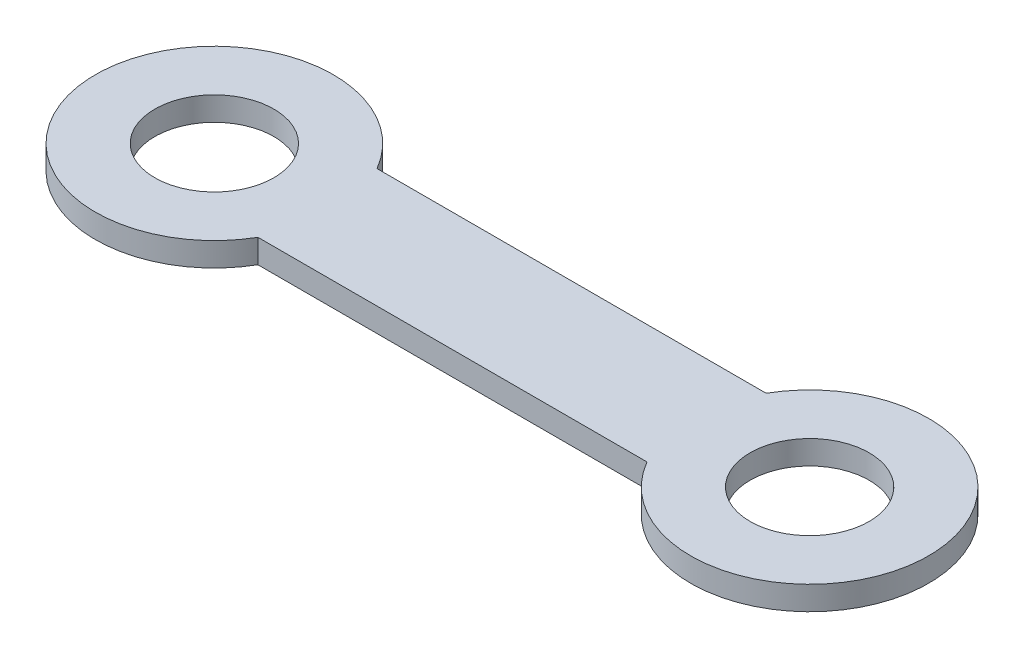
from build123d import *

# Parameters (mm, degrees)
SKETCH_5_R      = 5
EXTRUDE_1_DEPTH = 2


with BuildPart() as part:
    # 草圖5 → 填料-伸長1 (new body)
    with BuildSketch(Plane(origin=(0, 0, 0), x_dir=(1, 0, 0), z_dir=(0, 1, 0))):
        with BuildLine():
            Line((8.660254038, -5), (41.339745962, -5))
            ThreePointArc((41.339745962, -5), (60, 0), (41.339745962, 5))
            Line((41.339745962, 5), (8.660254038, 5))
            ThreePointArc((8.660254038, 5), (-10, 0), (8.660254038, -5))
        make_face()
        Circle(SKETCH_5_R, mode=Mode.SUBTRACT)
        with Locations((50, 0)):
            Circle(SKETCH_5_R, mode=Mode.SUBTRACT)
    extrude(amount=EXTRUDE_1_DEPTH)


solid = part.part
